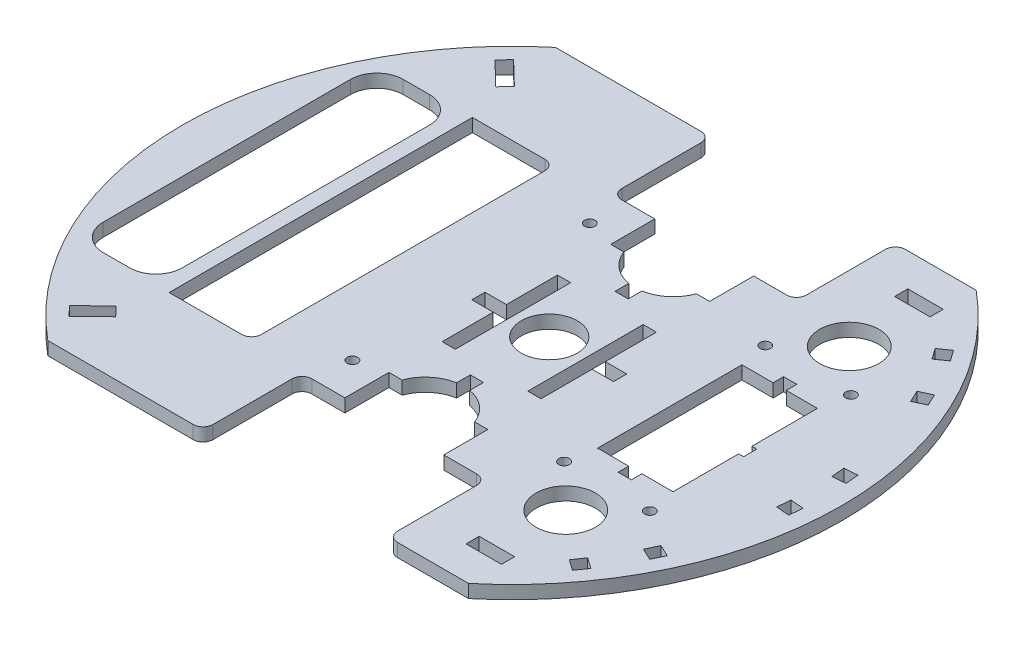
from build123d import *

# Parameters (mm, degrees)
SKETCH1_W           = 10.75
SKETCH1_H           = 4
SKETCH1_R           = 1.6
SKETCH1_R_2         = 9
SKETCH1_R_3         = 8.5
BOSS_EXTRUDE1_DEPTH = 4
FILLET2_R           = 3


with BuildPart() as part:
    # Sketch1 → Boss-Extrude1 (new body)
    with BuildSketch(Plane(origin=(0, 101.33365526, 0), x_dir=(1, 0, 0), z_dir=(0, 1, 0))):
        with BuildLine():
            Line((99.937186027, -237.061198021), (99.937186027, -207.061198021))
            Line((99.937186027, -207.061198021), (112.937186027, -207.061198021))
            Line((112.937186027, -207.061198021), (112.937186027, -193.701198021))
            Line((112.937186027, -193.701198021), (116.937186027, -193.701198021))
            Line((116.937186027, -193.701198021), (116.937186027, -193.724971735))
            ThreePointArc((116.937186027, -193.724971735), (120.422613168, -188.743411519), (125.937186027, -186.183405518))
            Line((125.937186027, -186.183405518), (125.937186027, -182.011198021))
            Line((125.937186027, -182.011198021), (129.937186027, -182.011198021))
            Line((129.937186027, -182.011198021), (129.937186027, -186.183405518))
            ThreePointArc((129.937186027, -186.183405518), (135.451758886, -188.743411519), (138.937186027, -193.724971735))
            Line((138.937186027, -193.724971735), (138.937186027, -193.701198021))
            Line((138.937186027, -193.701198021), (142.937186027, -193.701198021))
            Line((142.937186027, -193.701198021), (142.937186027, -207.061198021))
            Line((142.937186027, -207.061198021), (155.937186027, -207.061198021))
            Line((155.937186027, -207.061198021), (155.937186027, -237.061198021))
            Line((155.937186027, -237.061198021), (180.437186027, -237.061198021))
            ThreePointArc((180.437186027, -237.061198021), (216.632797463, -160.061198021), (180.437186027, -83.061198021))
            Line((180.437186027, -83.061198021), (155.937186027, -83.061198021))
            Line((155.937186027, -83.061198021), (155.937186027, -113.061198021))
            Line((155.937186027, -113.061198021), (142.937186027, -113.061198021))
            Line((142.937186027, -113.061198021), (142.937186027, -126.421198021))
            Line((142.937186027, -126.421198021), (138.937186027, -126.421198021))
            Line((138.937186027, -126.421198021), (138.937186027, -126.397424307))
            ThreePointArc((138.937186027, -126.397424307), (135.451758886, -131.378984523), (129.937186027, -133.938990524))
            Line((129.937186027, -133.938990524), (129.937186027, -138.111198021))
            Line((129.937186027, -138.111198021), (125.937186027, -138.111198021))
            Line((125.937186027, -138.111198021), (125.937186027, -133.938990524))
            ThreePointArc((125.937186027, -133.938990524), (120.422613168, -131.378984523), (116.937186027, -126.397424307))
            Line((116.937186027, -126.397424307), (116.937186027, -126.421198021))
            Line((116.937186027, -126.421198021), (112.937186027, -126.421198021))
            Line((112.937186027, -126.421198021), (112.937186027, -113.061198021))
            Line((112.937186027, -113.061198021), (99.937186027, -113.061198021))
            Line((99.937186027, -113.061198021), (99.937186027, -83.061198021))
            Line((99.937186027, -83.061198021), (52.828408899, -83.061198021))
            ThreePointArc((52.828408899, -83.061198021), (16.632797463, -160.061198021), (52.828408899, -237.061198021))
            Line((52.828408899, -237.061198021), (99.937186027, -237.061198021))
        make_face()
        with Locations((175.062186027, -95.061198021)):
            Rectangle(SKETCH1_W, SKETCH1_H, mode=Mode.SUBTRACT)
        Polygon((56.893376849, -220.531213103), (49.699978846, -227.477796808), (46.921345364, -224.600437606), (54.114743367, -217.653853902), align=None, mode=Mode.SUBTRACT)
        with Locations((104.217909851, -196.061198021)):
            Circle(SKETCH1_R, mode=Mode.SUBTRACT)
        Polygon((116.937186027, -142.561198021), (116.937186027, -177.561198021), (112.937186027, -177.561198021), (112.937186027, -162.061198021), (106.437186027, -162.061198021), (106.437186027, -158.061198021), (112.937186027, -158.061198021), (112.937186027, -142.561198021), align=None, mode=Mode.SUBTRACT)
        with Locations((175.062186027, -225.061198021)):
            Rectangle(SKETCH1_W, SKETCH1_H, mode=Mode.SUBTRACT)
        with Locations((175.937186027, -203.061198021)):
            Circle(SKETCH1_R_2, mode=Mode.SUBTRACT)
        Polygon((192.781361608, -217.850313996), (189.504753431, -215.55600825), (191.799059176, -212.279400073), (195.075667353, -214.573705818), align=None, mode=Mode.SUBTRACT)
        Polygon((201.615472458, -203.246431106), (197.990241309, -201.555958059), (199.680714356, -197.930726911), (203.305945504, -199.621199958), align=None, mode=Mode.SUBTRACT)
        with Locations((162.937186027, -190.561198021)):
            Circle(SKETCH1_R, mode=Mode.SUBTRACT)
        Polygon((138.937186027, -142.561198021), (142.937186027, -142.561198021), (142.937186027, -158.061198021), (149.437186027, -158.061198021), (149.437186027, -162.061198021), (142.937186027, -162.061198021), (142.937186027, -177.561198021), (138.937186027, -177.561198021), align=None, mode=Mode.SUBTRACT)
        with Locations((188.937186027, -190.561198021)):
            Circle(SKETCH1_R, mode=Mode.SUBTRACT)
        Polygon((173.937186027, -138.161198021), (173.937186027, -134.961198021), (177.937186027, -134.961198021), (177.937186027, -138.161198021), (187.387186027, -138.161198021), (187.387186027, -158.061198021), (188.887186027, -158.061198021), (188.887186027, -162.061198021), (187.387186027, -162.061198021), (187.387186027, -181.961198021), (177.937186027, -181.961198021), (177.937186027, -185.161198021), (173.937186027, -185.161198021), (173.937186027, -181.961198021), (164.487186027, -181.961198021), (164.487186027, -138.161198021), align=None, mode=Mode.SUBTRACT)
        Polygon((211.08596232, -170.585781918), (207.101183528, -170.237158947), (207.449806499, -166.252380154), (211.434585291, -166.601003125), align=None, mode=Mode.SUBTRACT)
        with BuildLine():
            ThreePointArc((30.129612814, -122.561198021), (32.472758565, -116.904343772), (38.129612814, -114.561198021))
            Line((38.129612814, -114.561198021), (46.129612814, -114.561198021))
            ThreePointArc((46.129612814, -114.561198021), (51.786467064, -116.904343772), (54.129612814, -122.561198021))
            Line((54.129612814, -122.561198021), (54.129612814, -197.561198021))
            ThreePointArc((54.129612814, -197.561198021), (51.786467064, -203.21805227), (46.129612814, -205.561198021))
            Line((46.129612814, -205.561198021), (38.129612814, -205.561198021))
            ThreePointArc((38.129612814, -205.561198021), (32.472758565, -203.21805227), (30.129612814, -197.561198021))
            Line((30.129612814, -197.561198021), (30.129612814, -122.561198021))
        make_face(mode=Mode.SUBTRACT)
        with BuildLine():
            Line((58.629612814, -206.061198021), (58.629612814, -114.061198021))
            Line((58.629612814, -114.061198021), (80.629612814, -114.061198021))
            ThreePointArc((80.629612814, -114.061198021), (82.750933158, -114.939877677), (83.629612814, -117.061198021))
            Line((83.629612814, -117.061198021), (83.629612814, -203.061198021))
            ThreePointArc((83.629612814, -203.061198021), (82.750933158, -205.182518365), (80.629612814, -206.061198021))
            Line((80.629612814, -206.061198021), (58.629612814, -206.061198021))
        make_face(mode=Mode.SUBTRACT)
        with Locations((104.217909851, -124.061198021)):
            Circle(SKETCH1_R, mode=Mode.SUBTRACT)
        Polygon((54.114743367, -102.46854214), (46.921345364, -95.521958436), (49.699978846, -92.644599234), (56.893376849, -99.591182939), align=None, mode=Mode.SUBTRACT)
        with Locations((127.937186027, -160.061198021)):
            Circle(SKETCH1_R_3, mode=Mode.SUBTRACT)
        with Locations((162.937186027, -129.561198021)):
            Circle(SKETCH1_R, mode=Mode.SUBTRACT)
        Polygon((211.434585291, -153.521392917), (207.449806499, -153.870015888), (207.101183528, -149.885237095), (211.08596232, -149.536614124), align=None, mode=Mode.SUBTRACT)
        with Locations((188.937186027, -129.561198021)):
            Circle(SKETCH1_R, mode=Mode.SUBTRACT)
        with Locations((175.937186027, -117.061198021)):
            Circle(SKETCH1_R_2, mode=Mode.SUBTRACT)
        Polygon((203.305945504, -120.501196084), (199.680714356, -122.191669131), (197.990241309, -118.566437983), (201.615472457, -116.875964936), align=None, mode=Mode.SUBTRACT)
        Polygon((195.075667353, -105.548690224), (191.799059176, -107.842995969), (189.504753431, -104.566387792), (192.781361608, -102.272082046), align=None, mode=Mode.SUBTRACT)
    extrude(amount=BOSS_EXTRUDE1_DEPTH)

    # Fillet2
    fillet2_edges = [part.edges().sort_by_distance(p)[0] for p in [
        (99.937186027, 103.33365526, 83.061198021),
        (99.937186027, 103.33365526, 113.061198021),
        (155.937186027, 103.33365526, 113.061198021),
        (155.937186027, 103.33365526, 83.061198021),
        (155.937186027, 103.33365526, 237.061198021),
        (155.937186027, 103.33365526, 207.061198021),
        (99.937186027, 103.33365526, 207.061198021),
        (99.937186027, 103.33365526, 237.061198021),
    ]]
    fillet(fillet2_edges, radius=FILLET2_R)


solid = part.part
